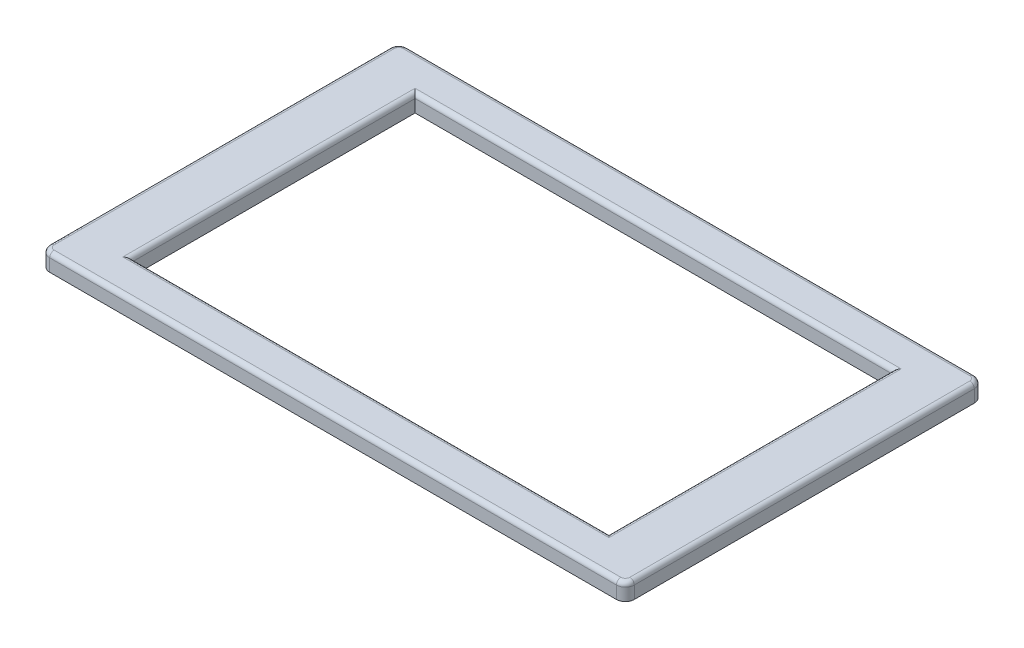
from build123d import *

# Parameters (mm, degrees)
CROQUIS1_W              = 160
CROQUIS1_H              = 95
SALIENTE_EXTRUIR3_DEPTH = 5.7
REDONDEO2_R             = 1.5
CROQUIS2_R              = 2
CORTAR_EXTRUIR1_DEPTH   = 3.1


with BuildPart() as part:
    # Croquis1 → Saliente-Extruir3 (new body)
    with BuildSketch(Plane(origin=(0, 0, 0), x_dir=(1, 0, 0), z_dir=(0, 1, 0))):
        with BuildLine():
            Line((4, 120), (194, 120))
            ThreePointArc((194, 120), (196.121320344, 119.121320344), (197, 117))
            Line((197, 117), (197, 3))
            ThreePointArc((197, 3), (196.121320344, 0.878679656), (194, 0))
            Line((194, 0), (4, 0))
            ThreePointArc((4, 0), (1.878679656, 0.878679656), (1, 3))
            Line((1, 3), (1, 117))
            ThreePointArc((1, 117), (1.878679656, 119.121320344), (4, 120))
        make_face()
        with Locations((99, 60)):
            Rectangle(CROQUIS1_W, CROQUIS1_H, mode=Mode.SUBTRACT)
    extrude(amount=SALIENTE_EXTRUIR3_DEPTH)

    # Redondeo2
    redondeo2_edges = [part.edges().sort_by_distance(p)[0] for p in [
        (1.878679656, 5.7, -0.878679656),
        (99, 5.7, 0),
        (196.121320344, 5.7, -0.878679656),
        (197, 5.7, -60),
        (196.121320344, 5.7, -119.121320344),
        (99, 5.7, -120),
        (99, 5.7, -107.5),
        (19, 5.7, -60),
        (99, 5.7, -12.5),
        (179, 5.7, -60),
        (1.878679656, 5.7, -119.121320344),
        (1, 5.7, -60),
    ]]
    fillet(redondeo2_edges, radius=REDONDEO2_R)

    # Croquis2 → Cortar-Extruir1 (cut)
    with BuildSketch(Plane.XZ):
        with Locations((5, -27.38768366)):
            Circle(CROQUIS2_R)
        with Locations((5, -87.38768366)):
            Circle(CROQUIS2_R)
        with Locations((193, -27.38768366)):
            Circle(CROQUIS2_R)
        with Locations((193, -87.38768366)):
            Circle(CROQUIS2_R)
    extrude(amount=-CORTAR_EXTRUIR1_DEPTH, mode=Mode.SUBTRACT)


solid = part.part
